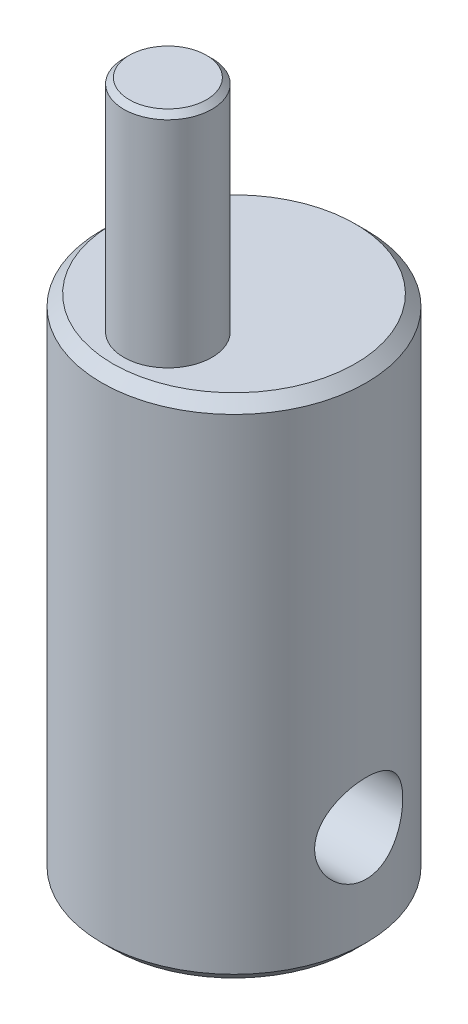
from build123d import *

# Parameters (mm, degrees)
SKETCH1_R               = 3
BOSS_EXTRUDE1_DEPTH     = 11.5
SKETCH4_R               = 1
BOSS_EXTRUDE2_DEPTH     = 5
SKETCH9_R               = 1
CUT_EXTRUDE1_DEPTH      = 4
CUT_EXTRUDE1_DEPTH_BACK = 4
CHAMFER1_SIZE           = 0.25
CHAMFER2_SIZE           = 0.25
CHAMFER3_SIZE           = 0.125


with BuildPart() as part:
    # Sketch1 → Boss-Extrude1 (new body)
    with BuildSketch(Plane(origin=(0, 0, 0), x_dir=(1, 0, 0), z_dir=(0, 1, 0))):
        Circle(SKETCH1_R)
    extrude(amount=BOSS_EXTRUDE1_DEPTH)

    # Sketch4 → Boss-Extrude2 (add)
    with BuildSketch(Plane(origin=(0, 11.5, 0), x_dir=(1, 0, 0), z_dir=(0, 1, 0))):
        with Locations((0, -1.5)):
            Circle(SKETCH4_R)
    extrude(amount=BOSS_EXTRUDE2_DEPTH)

    # Sketch9 → Cut-Extrude1 (cut, two sides)
    with BuildSketch(Plane(origin=(0, 0, 0), x_dir=(0, 0, -1), z_dir=(1, 0, 0))) as cut_extrude1_sk:
        with Locations((0, 2.5)):
            Circle(SKETCH9_R)
    extrude(amount=CUT_EXTRUDE1_DEPTH, mode=Mode.SUBTRACT)
    extrude(cut_extrude1_sk.sketch, amount=-CUT_EXTRUDE1_DEPTH_BACK, mode=Mode.SUBTRACT)

    # Chamfer1
    chamfer1_edges = [part.edges().sort_by_distance(p)[0] for p in [
        (-3, 11.5, 0),
    ]]
    chamfer(chamfer1_edges, length=CHAMFER1_SIZE)

    # Chamfer2
    chamfer2_edges = [part.edges().sort_by_distance(p)[0] for p in [
        (-3, 0, 0),
    ]]
    chamfer(chamfer2_edges, length=CHAMFER2_SIZE)

    # Chamfer3
    chamfer3_edges = [part.edges().sort_by_distance(p)[0] for p in [
        (-1, 16.5, 1.5),
    ]]
    chamfer(chamfer3_edges, length=CHAMFER3_SIZE)


solid = part.part
